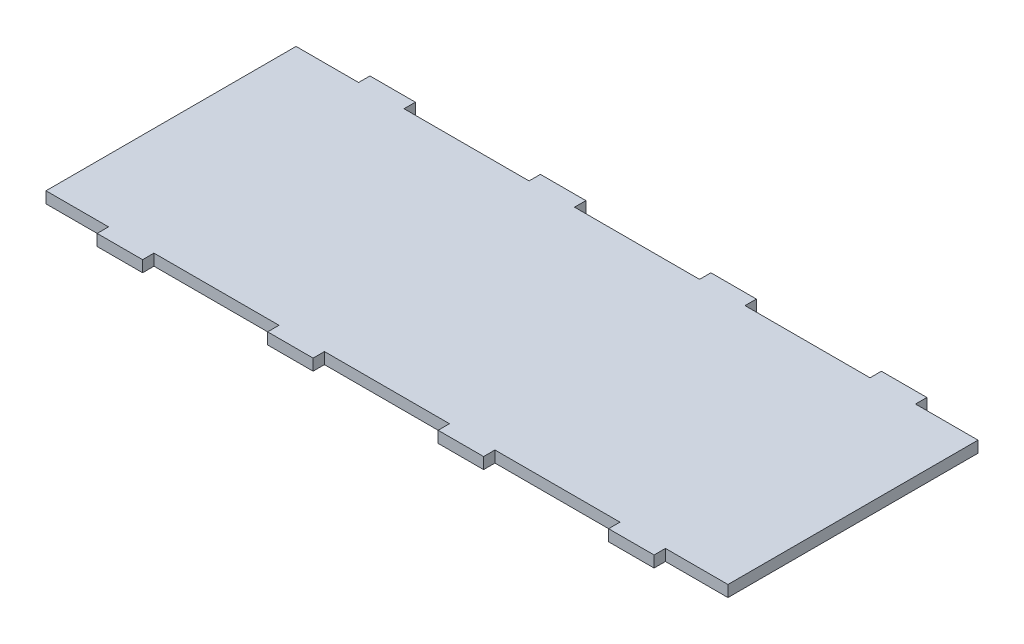
from build123d import *

# Parameters (mm, degrees)
SKETCH1_W               = 381
SKETCH1_H               = 152.4
BOSS_EXTRUDE1_DEPTH     = 6.35
SKETCH2_W               = 69.85
SKETCH2_H               = 6.35
CUT_EXTRUDE2_DEPTH      = 7.35
LPATTERN1_COUNT         = 3
LPATTERN1_PITCH         = 95.25
LPATTERN1_COL_COUNT     = 3
LPATTERN1_COL_PITCH     = 95.25
MIRROR2_COPY_1_SKETCH_W = 69.85
MIRROR2_COPY_1_SKETCH_H = 6.35
MIRROR2_COPY_1_DEPTH    = 7.35
MIRROR2_COPY_2_SKETCH_W = 69.85
MIRROR2_COPY_2_SKETCH_H = 6.35
MIRROR2_COPY_2_DEPTH    = 7.35
MIRROR2_COPY_3_SKETCH_W = 69.85
MIRROR2_COPY_3_SKETCH_H = 6.35
MIRROR2_COPY_3_DEPTH    = 7.35
MIRROR2_COPY_4_SKETCH_W = 69.85
MIRROR2_COPY_4_SKETCH_H = 6.35
MIRROR2_COPY_4_DEPTH    = 7.35


with BuildPart() as part:
    # Sketch1 → Boss-Extrude1 (new body)
    with BuildSketch(Plane(origin=(0, 0, 0), x_dir=(1, 0, 0), z_dir=(0, 1, 0))):
        Rectangle(SKETCH1_W, SKETCH1_H)
    extrude(amount=BOSS_EXTRUDE1_DEPTH)

    # Sketch2 → Cut-Extrude2 (cut, through all)
    with BuildSketch(Plane(origin=(0, 6.35, 0), x_dir=(1, 0, 0), z_dir=(0, 1, 0))):
        with Locations((0, -73.025)):
            Rectangle(SKETCH2_W, SKETCH2_H)
    cut_extrude2 = extrude(amount=-CUT_EXTRUDE2_DEPTH, mode=Mode.SUBTRACT)

    # LPattern1: Cut-Extrude2 ×3
    with Locations(*[(-i * LPATTERN1_PITCH, 0, 0) for i in range(1, LPATTERN1_COUNT)]):
        add(cut_extrude2, mode=Mode.SUBTRACT)

    # LPattern1 col: Cut-Extrude2 ×3
    with Locations(*[(i * LPATTERN1_COL_PITCH, 0, 0) for i in range(1, LPATTERN1_COL_COUNT)]):
        add(cut_extrude2, mode=Mode.SUBTRACT)

    # Mirror2: Cut-Extrude2 across plane
    add(cut_extrude2.mirror(Plane.XY), mode=Mode.SUBTRACT)

    # Mirror2 copy 1 sketch → Mirror2 copy 1 (cut, through all)
    with BuildSketch(Plane(origin=(-95.25, 6.35, 0), x_dir=(1, 0, 0), z_dir=(0, 1, 0))):
        with Locations((0, 73.025)):
            Rectangle(MIRROR2_COPY_1_SKETCH_W, MIRROR2_COPY_1_SKETCH_H)
    extrude(amount=-MIRROR2_COPY_1_DEPTH, mode=Mode.SUBTRACT)

    # Mirror2 copy 2 sketch → Mirror2 copy 2 (cut, through all)
    with BuildSketch(Plane(origin=(-190.5, 6.35, 0), x_dir=(1, 0, 0), z_dir=(0, 1, 0))):
        with Locations((0, 73.025)):
            Rectangle(MIRROR2_COPY_2_SKETCH_W, MIRROR2_COPY_2_SKETCH_H)
    extrude(amount=-MIRROR2_COPY_2_DEPTH, mode=Mode.SUBTRACT)

    # Mirror2 copy 3 sketch → Mirror2 copy 3 (cut, through all)
    with BuildSketch(Plane(origin=(95.25, 6.35, 0), x_dir=(1, 0, 0), z_dir=(0, 1, 0))):
        with Locations((0, 73.025)):
            Rectangle(MIRROR2_COPY_3_SKETCH_W, MIRROR2_COPY_3_SKETCH_H)
    extrude(amount=-MIRROR2_COPY_3_DEPTH, mode=Mode.SUBTRACT)

    # Mirror2 copy 4 sketch → Mirror2 copy 4 (cut, through all)
    with BuildSketch(Plane(origin=(190.5, 6.35, 0), x_dir=(1, 0, 0), z_dir=(0, 1, 0))):
        with Locations((0, 73.025)):
            Rectangle(MIRROR2_COPY_4_SKETCH_W, MIRROR2_COPY_4_SKETCH_H)
    extrude(amount=-MIRROR2_COPY_4_DEPTH, mode=Mode.SUBTRACT)


solid = part.part
